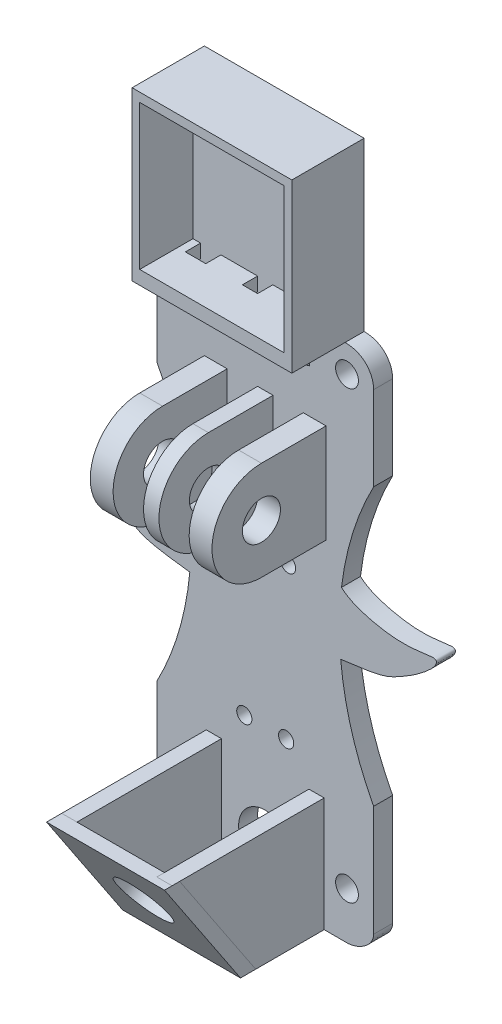
from build123d import *

# Parameters (mm, degrees)
MODEL_R              = 1.5
EXTRUDE_1_DEPTH      = 2.5
SKETCH_2_W           = 21
SKETCH_2_H           = 22
SKETCH_2_W_2         = 19
SKETCH_2_H_2         = 19.020798255
EXTRUDE_2_DEPTH      = 7
SKETCH_3_W           = 1.5
SKETCH_3_H           = 5
EXTRUDE_3_DEPTH      = 7
CUT_EXTRUDE_2_DEPTH  = 7
EXTRUDE_6_DEPTH      = 7
CUT_EXTRUDE_4_DEPTH  = 7
SKETCH_13_W          = 2
SKETCH_13_H          = 2
CUT_EXTRUDE_5_DEPTH  = 7
EXTRUDE_7_DEPTH      = 20
CUT_EXTRUDE_6_DEPTH  = 20
SKETCH_20_W          = 15.5
SKETCH_20_H          = 18.027756377
EXTRUDE_9_DEPTH      = 1
SKETCH_21_R          = 3.5
CUT_EXTRUDE_7_DEPTH  = 2
SKETCH_23_R          = 3.5
CUT_EXTRUDE_8_DEPTH  = 4
SKETCH_25_W          = 3
SKETCH_25_H          = 13
EXTRUDE_10_DEPTH     = 15
SKETCH_26_R          = 2.5
CUT_EXTRUDE_9_DEPTH  = 18
CUT_EXTRUDE_10_DEPTH = 16
SKETCH_28_W          = 2.683621922
SKETCH_28_H          = 2
CUT_EXTRUDE_12_DEPTH = 2
SKETCH_30_R          = 1
CUT_EXTRUDE_13_DEPTH = 10
SKETCH_31_R          = 39
CUT_EXTRUDE_14_DEPTH = 10
SKETCH_33_R          = 1
CUT_EXTRUDE_15_DEPTH = 2.5
EXTRUDE_13_DEPTH     = 2.5


with BuildPart() as part:
    # Model → 凸台-拉伸1 (new body)
    with BuildSketch(Plane.XY):
        with BuildLine():
            Line((35.686511473, 106.179045823), (14.686511473, 106.179045823))
            Line((14.686511473, 106.179045823), (14.686511473, 84.179045823))
            add(Edge.make_bspline(
                [(14.686511473, 84.179045823), (12.217125861, 84.179045823), (10.936511473, 82.388902867), (10.936511473, 80.679045823)],
                knots=[0, 0, 0, 0, 5.129571132, 5.129571132, 5.129571132, 5.129571132], degree=3))
            Line((10.936511473, 80.679045823), (10.936511473, 18.679045823))
            add(Edge.make_bspline(
                [(10.936511473, 18.679045823), (10.936511473, 17.199254946), (12.956720596, 15.948106541), (14.436511473, 15.948106541)],
                knots=[0, 0, 0, 0, 4.439372631, 4.439372631, 4.439372631, 4.439372631], degree=3))
            Line((14.436511473, 15.948106541), (35.936511473, 15.948106541))
            add(Edge.make_bspline(
                [(39.436511473, 18.679045823), (39.436511473, 17.199254946), (37.41630235, 15.948106541), (35.936511473, 15.948106541)],
                knots=[0, 0, 0, 0, 4.439372631, 4.439372631, 4.439372631, 4.439372631], degree=3))
            Line((39.436511473, 18.679045823), (39.436511473, 80.679045823))
            add(Edge.make_bspline(
                [(35.686511473, 84.179045823), (38.155897084, 84.179045823), (39.436511473, 82.388902867), (39.436511473, 80.679045823)],
                knots=[0, 0, 0, 0, 5.129571132, 5.129571132, 5.129571132, 5.129571132], degree=3))
            Line((35.686511473, 84.179045823), (35.686511473, 106.179045823))
        make_face()
        with Locations((14.436511473, 22.132696196)):
            Circle(MODEL_R, mode=Mode.SUBTRACT)
        with Locations((35.936511473, 22.132696196)):
            Circle(MODEL_R, mode=Mode.SUBTRACT)
        with Locations((14.436511473, 80.679045823)):
            Circle(MODEL_R, mode=Mode.SUBTRACT)
        with Locations((35.936511473, 80.679045823)):
            Circle(MODEL_R, mode=Mode.SUBTRACT)
    extrude(amount=EXTRUDE_1_DEPTH)

    # 草图2 → 凸台-拉伸2 (add)
    with BuildSketch(Plane.XY.offset(2.5)):
        with Locations((25.186511473, 95.179045823)):
            Rectangle(SKETCH_2_W, SKETCH_2_H)
        with Locations((25.18651147, 95.501249058)):
            Rectangle(SKETCH_2_W_2, SKETCH_2_H_2, mode=Mode.SUBTRACT)
    extrude(amount=EXTRUDE_2_DEPTH)

    # 草图3 → 凸台-拉伸3 (add)
    with BuildSketch(Plane.XY.offset(2.5)):
        with Locations((20.120133395, 81.679045823)):
            Rectangle(SKETCH_3_W, SKETCH_3_H)
    extrude(amount=EXTRUDE_3_DEPTH)

    # 草图4 → 切除-拉伸2 (cut)
    with BuildSketch(Plane.ZY.offset(-19.370133395)):
        Polygon((9.5, 84.179045823), (2.5, 79.179045823), (9.5, 79.179045823), align=None)
    extrude(amount=-CUT_EXTRUDE_2_DEPTH, mode=Mode.SUBTRACT)

    # Sketch 3D_1 → 凸台-拉伸6 (add)
    with BuildSketch(Plane(origin=(31.006511473, 84.179045823, 2.5), x_dir=(-0.28734788556634544, -0.9578262852211514, 0), z_dir=(0, 0, -1))):
        Polygon((0, 0), (0.431021828, 1.436739428), (5.220153254, 0), (4.789131426, -1.436739428), align=None)
    extrude(amount=-EXTRUDE_6_DEPTH)

    # 草图12 → 切除-拉伸4 (cut)
    with BuildSketch(Plane.ZY.offset(-29.506511473)):
        Polygon((9.5, 84.179045823), (9.5, 79.179045823), (2.5, 79.179045823), align=None)
    extrude(amount=-CUT_EXTRUDE_4_DEPTH, mode=Mode.SUBTRACT)

    # 草图13 → 切除-拉伸5 (cut)
    with BuildSketch(Plane.XZ.offset(-84.179045823)):
        with Locations((25.186511473, 3.5)):
            Rectangle(SKETCH_13_W, SKETCH_13_H)
    extrude(amount=-CUT_EXTRUDE_5_DEPTH, mode=Mode.SUBTRACT)

    # 草图14 → 凸台-拉伸7 (add)
    with BuildSketch(Plane.XY.offset(2.5)):
        Polygon((19.436511473, 30.948106541), (19.436511473, 17.948106541), (30.936511473, 17.948106541), (30.936511473, 30.948106541), (32.936511473, 30.948106541), (32.936511473, 15.948106541), (17.436511473, 15.948106541), (17.436511473, 30.948106541), align=None)
    extrude(amount=EXTRUDE_7_DEPTH)

    # 草图15 → 切除-拉伸6 (cut)
    with BuildSketch(Plane.ZY.offset(-17.436511473)):
        Polygon((22.5, 30.948106541), (22.5, 15.948106541), (12.5, 15.948106541), align=None)
    extrude(amount=-CUT_EXTRUDE_6_DEPTH, mode=Mode.SUBTRACT)

    # 草图23 → 切除-拉伸8 (cut)
    with BuildSketch(Plane.XY.offset(2.5)):
        with Locations((25.186511473, 22.179045823)):
            Circle(SKETCH_23_R)
    extrude(amount=-CUT_EXTRUDE_8_DEPTH, mode=Mode.SUBTRACT)

    # 草图25 → 凸台-拉伸10 (add)
    with BuildSketch(Plane.XY.offset(2.5)):
        Polygon((25.186511473, 73.429045823), (26.214511031, 73.429045823), (26.214511031, 60.429045823), (24.186511473, 60.429045823), (24.186511473, 73.429045823), align=None)
        with Locations((31.686511473, 66.929045823)):
            Rectangle(SKETCH_25_W, SKETCH_25_H)
        with Locations((18.686511473, 66.929045823)):
            Rectangle(SKETCH_25_W, SKETCH_25_H)
    extrude(amount=EXTRUDE_10_DEPTH)

    # 草图26 → 切除-拉伸9 (cut)
    with BuildSketch(Plane.ZY.offset(-17.186511473)):
        with Locations(Location((11, 66.929045823, 0), (0, 0, 270))):
            Circle(SKETCH_26_R)
    extrude(amount=-CUT_EXTRUDE_9_DEPTH, mode=Mode.SUBTRACT)

    # 草图27 → 切除-拉伸10 (cut)
    with BuildSketch(Plane.ZY.offset(-17.186511473)):
        with BuildLine():
            Line((11, 73.429045823), (11, 75.536501325))
            Line((11, 75.536501325), (21.747083052, 75.536501325))
            Line((21.747083052, 75.536501325), (21.747083052, 59.045875477))
            Line((21.747083052, 59.045875477), (11, 59.431370627))
            Line((11, 59.431370627), (11, 60.429045823))
            ThreePointArc((11, 60.429045823), (17.5, 66.929045823), (11, 73.429045823))
        make_face()
    extrude(amount=-CUT_EXTRUDE_10_DEPTH, mode=Mode.SUBTRACT)

    # 草图28 → 切除-拉伸12 (cut)
    with BuildSketch(Plane.XZ.offset(-84.179045823)):
        with Locations((18.028322434, 3.5)):
            Rectangle(SKETCH_28_W, SKETCH_28_H)
        Polygon((31.001439257, 2.495787232), (33.685060474, 2.493843259), (33.686509243, 4.493842734), (31.002888025, 4.495786707), align=None)
    extrude(amount=-CUT_EXTRUDE_12_DEPTH, mode=Mode.SUBTRACT)

    # 草图30 → 切除-拉伸13 (cut)
    with BuildSketch(Plane.XY.offset(2.5)):
        with Locations((28.188322434, 55.179045823)):
            Circle(SKETCH_30_R)
        with Locations((22.188322434, 54.179045823)):
            Circle(SKETCH_30_R)
    extrude(amount=-CUT_EXTRUDE_13_DEPTH, mode=Mode.SUBTRACT)

    # 草图31 → 切除-拉伸14 (cut)
    with BuildSketch(Plane.XY.offset(2.5)):
        with Locations((-23.563488527, 51.429045823)):
            Circle(SKETCH_31_R)
        with Locations((73.936511473, 51.429045823)):
            Circle(SKETCH_31_R)
    extrude(amount=-CUT_EXTRUDE_14_DEPTH, mode=Mode.SUBTRACT)

    # 草图33 → 切除-拉伸15 (cut)
    with BuildSketch(Plane.XY.offset(2.5)):
        with Locations((22.436511473, 35.132696196)):
            Circle(SKETCH_33_R)
        with Locations((27.936511473, 35.132696196)):
            Circle(SKETCH_33_R)
    extrude(amount=-CUT_EXTRUDE_15_DEPTH, mode=Mode.SUBTRACT)

    # 草图32 → 凸台-拉伸13 (add)
    with BuildSketch(Plane.XY.offset(2.5)):
        with BuildLine():
            Line((17.214511031, 60.429045823), (15.297431543, 47.822900451))
            add(Edge.make_bspline(
                [(17.214511031, 60.429045823), (16.402774166, 57.261824787), (15.879635601, 55.030502336), (6.038156358, 53.300869438), (2.601041084, 54.562530921), (2.767654696, 53.014775012), (5.153806778, 51.137514182), (9.250259364, 48.687019635), (9.753110129, 48.526716356), (15.297431543, 47.822900451)],
                knots=[0, 0, 0, 0, 0.228683763, 0.270207351, 0.399121597, 0.431668139, 0.563126225, 0.621602637, 1, 1, 1, 1], degree=3))
        make_face()
        with BuildLine():
            Line((33.186511473, 60.429045823), (35.10359096, 47.822900451))
            add(Edge.make_bspline(
                [(33.186511473, 60.429045823), (33.998248337, 57.261824787), (34.521386902, 55.030502336), (44.362866145, 53.300869438), (47.79998142, 54.562530921), (47.633367808, 53.014775012), (45.247215725, 51.137514182), (41.150763139, 48.687019635), (40.647912374, 48.526716356), (35.10359096, 47.822900451)],
                knots=[0, 0, 0, 0, 0.228683763, 0.270207351, 0.399121597, 0.431668139, 0.563126225, 0.621602637, 1, 1, 1, 1], degree=3))
        make_face()
    extrude(amount=-EXTRUDE_13_DEPTH)


with BuildPart() as body_2:
    # 草图20 → 凸台-拉伸9 (new, symmetric, along a direction that is not the sketch's normal)
    with BuildSketch(Plane(origin=(0, -0.862121064, 1.293181596), x_dir=(1, 0, 0), z_dir=(0, -0.5547001962252294, 0.8320502943378436))):
        with Locations((25.186511473, 29.217257383)):
            Rectangle(SKETCH_20_W, SKETCH_20_H)
    extrude(amount=EXTRUDE_9_DEPTH, dir=(0, 0, 1), both=True)

    # 草图21 → 切除-拉伸7 (cut)
    with BuildSketch(Plane(origin=(0, -1.323659526, 1.985489289), x_dir=(1, 0, 0), z_dir=(0, -0.5547001962252295, 0.8320502943378434))):
        with Locations(Location((25.186511473, 29.771957579, 0), (0, 0, 270))):
            Circle(SKETCH_21_R)
    extrude(amount=-CUT_EXTRUDE_7_DEPTH, mode=Mode.SUBTRACT)


solid = Compound([part.part, body_2.part])
